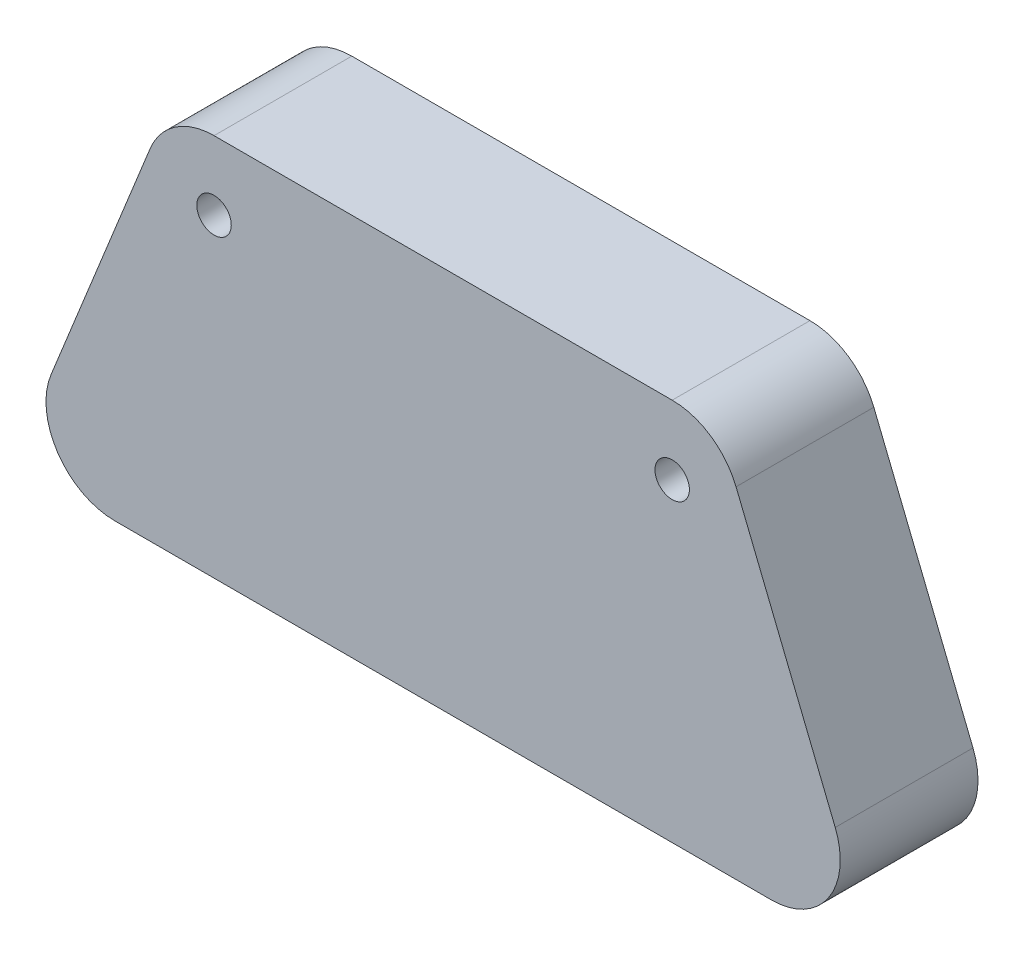
from build123d import *

# Parameters (mm, degrees)
SKETCH2_R           = 1.25
BOSS_EXTRUDE1_DEPTH = 10


with BuildPart() as part:
    # Sketch2 → Boss-Extrude1 (new body)
    with BuildSketch(Plane.XY):
        with BuildLine():
            Line((-8.808086989, 12.620893293), (24.446827843, 12.620893293))
            ThreePointArc((24.446827843, 12.620893293), (27.24279236, 11.766081155), (29.082747115, 9.49392626))
            Line((29.082747115, 9.49392626), (36.28068266, -8.321589377))
            ThreePointArc((36.28068266, -8.321589377), (35.78995125, -12.990586862), (31.644763387, -15.194622344))
            Line((31.644763387, -15.194622344), (-16.006022533, -15.194622344))
            ThreePointArc((-16.006022533, -15.194622344), (-20.151210396, -12.990586862), (-20.641941806, -8.321589377))
            Line((-20.641941806, -8.321589377), (-13.444006262, 9.49392626))
            ThreePointArc((-13.444006262, 9.49392626), (-11.604051506, 11.766081155), (-8.808086989, 12.620893293))
        make_face()
        with Locations((-8.808086989, 7.620893293)):
            Circle(SKETCH2_R, mode=Mode.SUBTRACT)
        with Locations((24.446827843, 7.620893293)):
            Circle(SKETCH2_R, mode=Mode.SUBTRACT)
    extrude(amount=BOSS_EXTRUDE1_DEPTH)


solid = part.part
